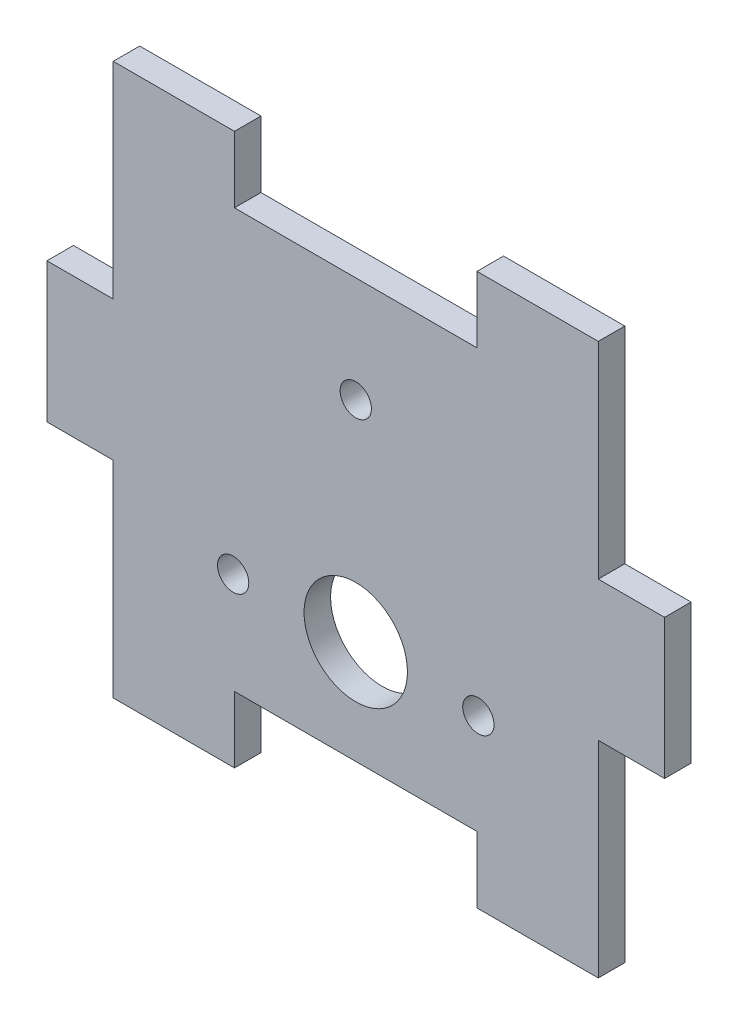
from build123d import *

# Parameters (mm, degrees)
SKETCH1_W           = 46.482
SKETCH1_H           = 40.132
BOSS_EXTRUDE1_DEPTH = 1.27
SKETCH2_W           = 11.6205
SKETCH2_H           = 6.35
SKETCH2_W_2         = 6.35
SKETCH2_H_2         = 13.377333334
BOSS_EXTRUDE2_DEPTH = 2.54
SKETCH3_R           = 1.5
SKETCH3_R_2         = 4.953
CUT_EXTRUDE1_DEPTH  = 3.54


with BuildPart() as part:
    # Sketch1 → Boss-Extrude1 (new body, symmetric)
    with BuildSketch(Plane.XY):
        Rectangle(SKETCH1_W, SKETCH1_H)
    extrude(amount=BOSS_EXTRUDE1_DEPTH, both=True)

    # Sketch2 → Boss-Extrude2 (add, through all)
    with BuildSketch(Plane.XY.offset(1.27)):
        with Locations((-17.43075, 23.241)):
            Rectangle(SKETCH2_W, SKETCH2_H)
        with Locations((17.43075, 23.241)):
            Rectangle(SKETCH2_W, SKETCH2_H)
        with Locations((-26.416, 0)):
            Rectangle(SKETCH2_W_2, SKETCH2_H_2)
        with Locations((26.416, 0)):
            Rectangle(SKETCH2_W_2, SKETCH2_H_2)
        with Locations((-17.43075, -23.241)):
            Rectangle(SKETCH2_W, SKETCH2_H)
        with Locations((17.43075, -23.241)):
            Rectangle(SKETCH2_W, SKETCH2_H)
    extrude(amount=-BOSS_EXTRUDE2_DEPTH)

    # Sketch3 → Cut-Extrude1 (cut, through all)
    with BuildSketch(Plane.XY.offset(1.27)):
        with Locations((0, 9.954)):
            Circle(SKETCH3_R)
        with Locations((0, -10.16)):
            Circle(SKETCH3_R_2)
        with Locations((-11.75, -10.397596989)):
            Circle(SKETCH3_R)
        with Locations((11.75, -10.397596989)):
            Circle(SKETCH3_R)
    extrude(amount=-CUT_EXTRUDE1_DEPTH, mode=Mode.SUBTRACT)


solid = part.part
